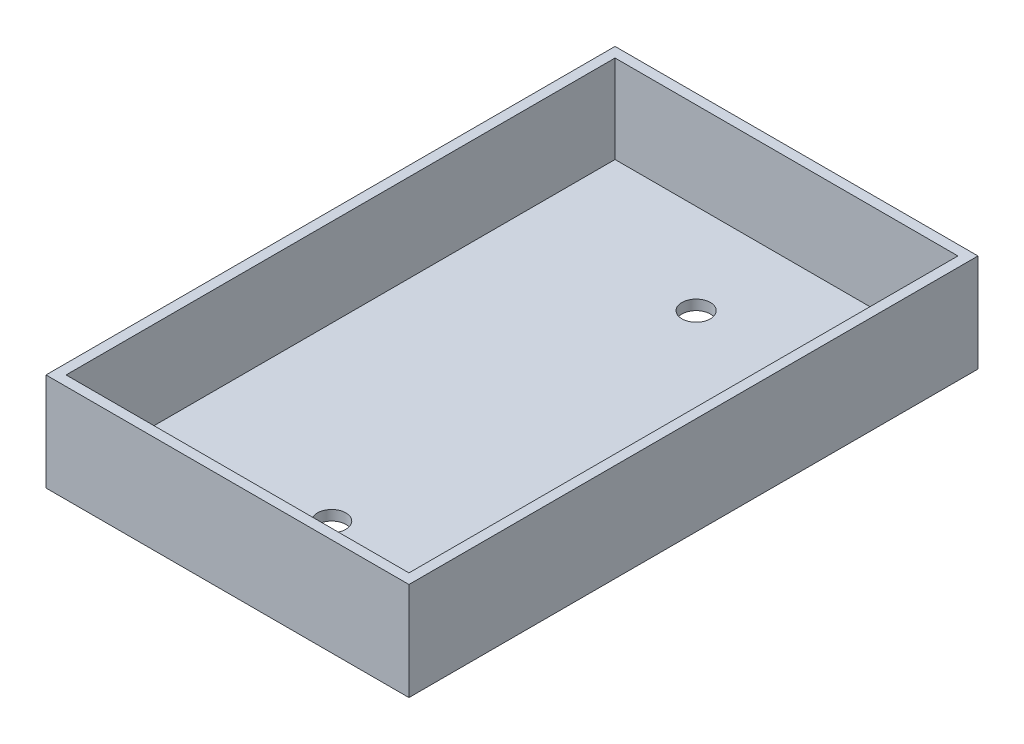
from build123d import *

# Parameters (mm, degrees)
SKETCH1_W                 = 57.404
SKETCH1_H                 = 90
BOSS_EXTRUDE1_DEPTH       = 1.5875
SKETCH2_W                 = 90
SKETCH2_H                 = 13.9065
BOSS_EXTRUDE2_DEPTH       = 1.5875
SKETCH3_W                 = 1.5875
SKETCH3_H                 = 13.9065
BOSS_EXTRUDE3_DEPTH       = 54.229
SKETCH4_W                 = 90
SKETCH4_H                 = 15.494
BOSS_EXTRUDE4_DEPTH       = 1.5875
F_8_CLEARANCE_HOLE1_D     = 4.4958
F_8_CLEARANCE_HOLE1_DEPTH = 1.5875


with BuildPart() as part:
    # Sketch1 → Boss-Extrude1 (new body)
    with BuildSketch(Plane(origin=(0, 0, 0), x_dir=(1, 0, 0), z_dir=(0, 1, 0))):
        with Locations((28.702, -45)):
            Rectangle(SKETCH1_W, SKETCH1_H)
    extrude(amount=BOSS_EXTRUDE1_DEPTH)

    # Sketch2 → Boss-Extrude2 (add)
    with BuildSketch(Plane(origin=(57.404, 0, 0), x_dir=(0, 0, -1), z_dir=(1, 0, 0))):
        with Locations((-45, 8.54075)):
            Rectangle(SKETCH2_W, SKETCH2_H)
    extrude(amount=-BOSS_EXTRUDE2_DEPTH)

    # Sketch3 → Boss-Extrude3 (add)
    with BuildSketch(Plane.ZY.offset(-55.8165)):
        with Locations((0.79375, 8.54075)):
            Rectangle(SKETCH3_W, SKETCH3_H)
        with Locations((89.20625, 8.54075)):
            Rectangle(SKETCH3_W, SKETCH3_H)
    extrude(amount=BOSS_EXTRUDE3_DEPTH)

    # Sketch4 → Boss-Extrude4 (add)
    with BuildSketch(Plane.ZY.offset(-1.5875)):
        with Locations((45, 7.747)):
            Rectangle(SKETCH4_W, SKETCH4_H)
    extrude(amount=BOSS_EXTRUDE4_DEPTH)

    # #8 Clearance Hole1
    with Locations(Plane(origin=(0, 1.5875, 0), x_dir=(1, 0, 0), z_dir=(0, 1, 0))):
        with Locations((28.702, -73.5203), (28.702, -15.875)):
            Hole(F_8_CLEARANCE_HOLE1_D / 2, depth=F_8_CLEARANCE_HOLE1_DEPTH)


solid = part.part
